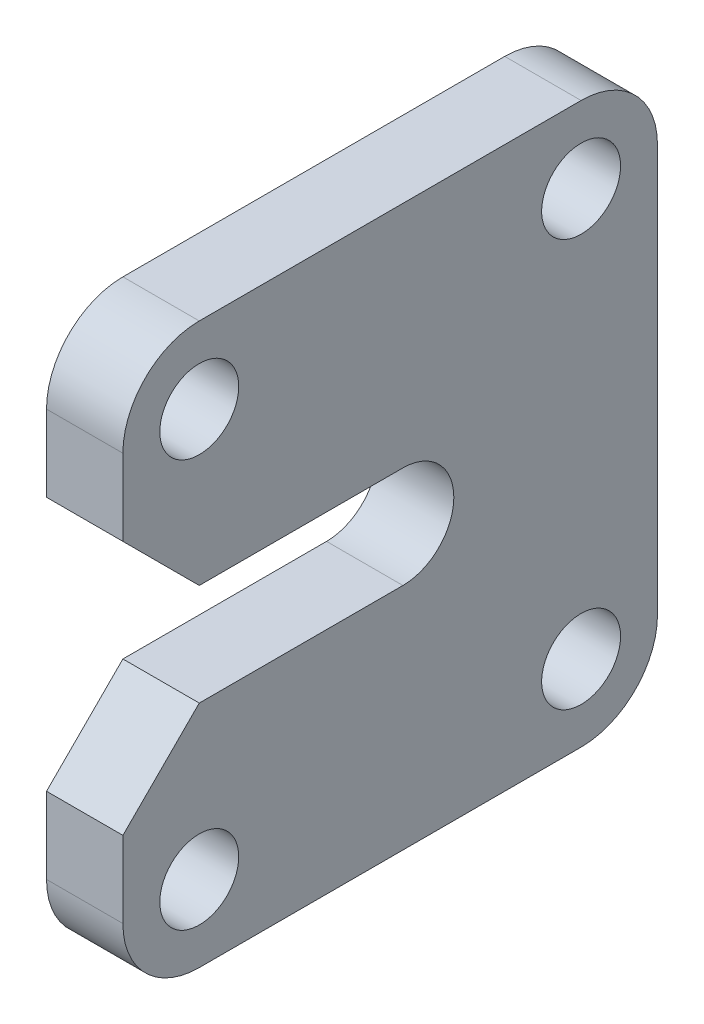
from build123d import *

# Parameters (mm, degrees)
SKETCH_1_R      = 1.55
EXTRUDE_1_DEPTH = 1.5
FILLET_1_R      = 3


with BuildPart() as part:
    # 草图1 → 凸台-拉伸1 (new body, symmetric)
    with BuildSketch(Plane(origin=(0, 0, 0), x_dir=(0, 0, -1), z_dir=(1, 0, 0))):
        with BuildLine():
            Line((-89, 11), (-89, -11))
            Line((-89, -11), (-110, -11))
            Line((-110, -11), (-110, -5))
            Line((-110, -5), (-107, -2))
            Line((-107, -2), (-99, -2))
            ThreePointArc((-99, -2), (-97, 0), (-99, 2))
            Line((-99, 2), (-107, 2))
            Line((-107, 2), (-110, 5))
            Line((-110, 5), (-110, 11))
            Line((-110, 11), (-89, 11))
        make_face()
        with Locations((-107, 8)):
            Circle(SKETCH_1_R, mode=Mode.SUBTRACT)
        with Locations((-92, 8)):
            Circle(SKETCH_1_R, mode=Mode.SUBTRACT)
        with Locations((-92, -8)):
            Circle(SKETCH_1_R, mode=Mode.SUBTRACT)
        with Locations((-107, -8)):
            Circle(SKETCH_1_R, mode=Mode.SUBTRACT)
    extrude(amount=EXTRUDE_1_DEPTH, both=True)

    # 圆角1
    fillet_1_edges = [part.edges().sort_by_distance(p)[0] for p in [
        (0, 11, 110),
        (0, 11, 89),
        (0, -11, 89),
        (0, -11, 110),
    ]]
    fillet(fillet_1_edges, radius=FILLET_1_R)


solid = part.part
